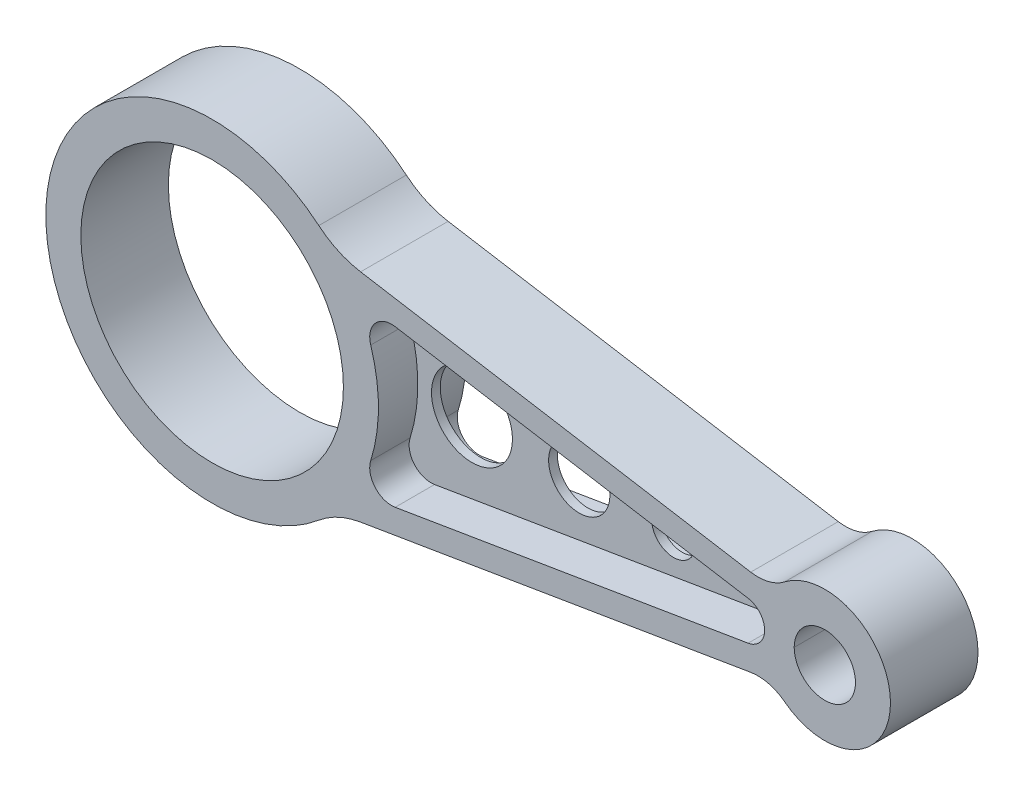
from build123d import *

# Parameters (mm, degrees)
SKETCH1_R           = 30
SKETCH1_R_2         = 7
BOSS_EXTRUDE1_DEPTH = 10
FILLET1_R           = 10
FILLET2_R           = 20
CUT_EXTRUDE1_DEPTH  = 9
SKETCH3_R           = 9.25
SKETCH3_R_2         = 7
SKETCH3_R_3         = 5
SKETCH3_R_4         = 3.023758928
CUT_EXTRUDE2_DEPTH  = 12


with BuildPart() as part:
    # Sketch1 → Boss-Extrude1 (new body, symmetric)
    with BuildSketch(Plane.XY):
        with BuildLine():
            Line((27.935473676, 25.760615491), (128.063755469, 9.084385863))
            ThreePointArc((128.063755469, 9.084385863), (155, 0), (128.063755469, -9.084385863))
            Line((128.063755469, -9.084385863), (27.935473676, -25.760615491))
            ThreePointArc((27.935473676, -25.760615491), (-38, 0), (27.935473676, 25.760615491))
        make_face()
        Circle(SKETCH1_R, mode=Mode.SUBTRACT)
        with Locations((140, 0)):
            Circle(SKETCH1_R_2, mode=Mode.SUBTRACT)
    extrude(amount=BOSS_EXTRUDE1_DEPTH, both=True)

    # Fillet1
    fillet1_edges = [part.edges().sort_by_distance(p)[0] for p in [
        (128.063755469, 9.084385863, 0),
        (128.063755469, -9.084385863, 0),
    ]]
    fillet(fillet1_edges, radius=FILLET1_R)

    # Fillet2
    fillet2_edges = [part.edges().sort_by_distance(p)[0] for p in [
        (27.935473676, 25.760615491, 0),
        (27.935473676, -25.760615491, 0),
    ]]
    fillet(fillet2_edges, radius=FILLET2_R)

    # Sketch2 → Cut-Extrude1 (cut)
    with BuildSketch(Plane.XY.offset(10)):
        with BuildLine():
            Line((41.828554558, 17.870982725), (122.478416149, 4.438857582))
            ThreePointArc((122.478416149, 4.438857582), (126.239130435, 0), (122.478416149, -4.438857582))
            Line((122.478416149, -4.438857582), (41.828554558, -17.870982725))
            ThreePointArc((41.828554558, -17.870982725), (37.231968897, -16.217361812), (36.238855523, -11.43439331))
            ThreePointArc((36.238855523, -11.43439331), (38, 0), (36.238855523, 11.43439331))
            ThreePointArc((36.238855523, 11.43439331), (37.231968897, 16.217361812), (41.828554558, 17.870982725))
        make_face()
    cut_extrude1 = extrude(amount=-CUT_EXTRUDE1_DEPTH, mode=Mode.SUBTRACT)

    # Mirror1: Cut-Extrude1 across plane
    add(cut_extrude1.mirror(Plane.XY), mode=Mode.SUBTRACT)

    # Sketch3 → Cut-Extrude2 (cut, through all)
    with BuildSketch(Plane.XY.offset(1)):
        with Locations((50.371368822, 0)):
            Circle(SKETCH3_R)
        with Locations((74.88991016, 0)):
            Circle(SKETCH3_R_2)
        with Locations((96.440508127, 0)):
            Circle(SKETCH3_R_3)
        with Locations((112.976627131, 0)):
            Circle(SKETCH3_R_4)
    extrude(amount=-CUT_EXTRUDE2_DEPTH, mode=Mode.SUBTRACT)


solid = part.part
